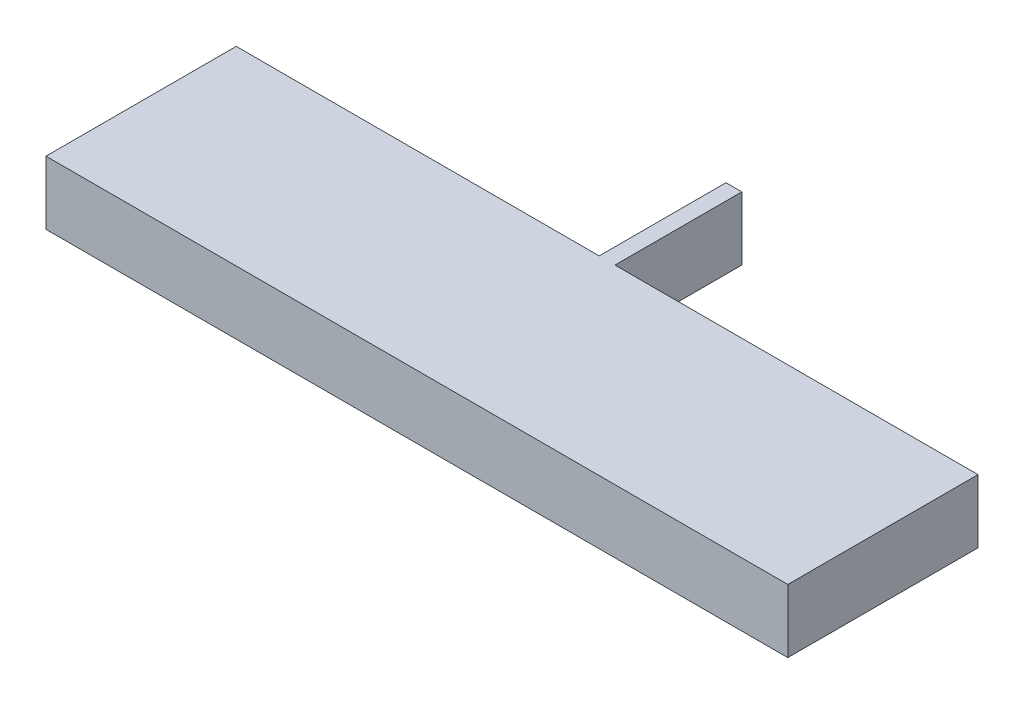
from build123d import *

# Parameters (mm, degrees)
BOSS_EXTRUDE1_DEPTH = 2


with BuildPart() as part:
    # Sketch1 → Boss-Extrude1 (new body)
    with BuildSketch(Plane(origin=(0, 0, 0), x_dir=(1, 0, 0), z_dir=(0, 1, 0))):
        Polygon((-11.7, 3), (-0.25, 3), (-0.25, 7), (0.25, 7), (0.25, 3), (11.7, 3), (11.7, -3), (-11.7, -3), align=None)
    extrude(amount=BOSS_EXTRUDE1_DEPTH)


solid = part.part
